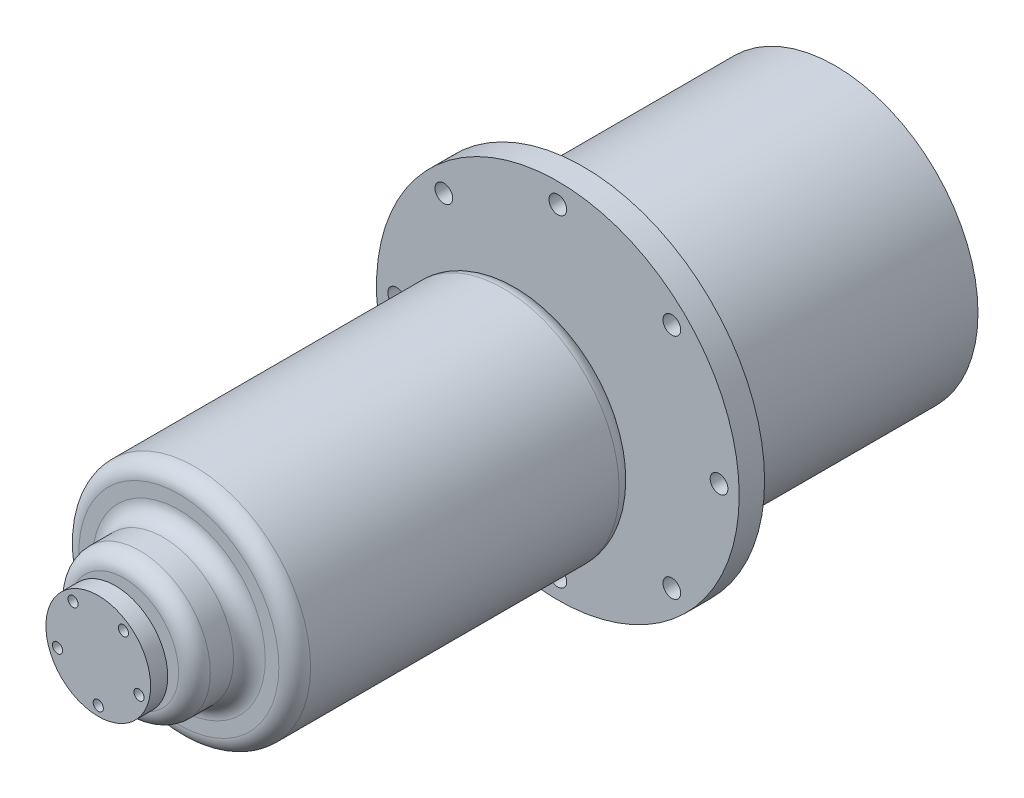
from build123d import *

# Parameters (mm, degrees)
SKETCH1_R          = 57.15
EXTRUDE1_DEPTH     = 4
SKETCH3_R          = 7.5
EXTRUDE2_DEPTH     = 12.166
SKETCH4_R          = 36.5
EXTRUDE3_DEPTH     = 107.24
SKETCH5_R          = 22.225
EXTRUDE4_DEPTH     = 17.3228
SKETCH6_R          = 9.525
EXTRUDE5_DEPTH     = 2.702052
SKETCH7_R          = 16.5
EXTRUDE6_DEPTH     = 5.3848
SKETCH8_R          = 1.6
CUT_EXTRUDE1_DEPTH = 5.3848
SKETCH10_R         = 2.79
CUT_EXTRUDE2_DEPTH = 8
SKETCH11_R         = 45
EXTRUDE7_DEPTH     = 79.4
FILLET1_R          = 5


with BuildPart() as part:
    # Sketch1 → Extrude1 (new body, symmetric)
    with BuildSketch(Plane.XY):
        Circle(SKETCH1_R)
    extrude(amount=EXTRUDE1_DEPTH, both=True)

    # Sketch3 → Extrude2 (add)
    with BuildSketch(Plane.XY.offset(4)):
        Circle(SKETCH3_R)
    extrude(amount=EXTRUDE2_DEPTH)

    # Sketch4 → Extrude3 (add)
    with BuildSketch(Plane.XY.offset(16.166)):
        Circle(SKETCH4_R)
    extrude(amount=EXTRUDE3_DEPTH)

    # Sketch5 → Extrude4 (add)
    with BuildSketch(Plane.XY.offset(123.406)):
        Circle(SKETCH5_R)
    extrude(amount=EXTRUDE4_DEPTH)

    # Sketch6 → Extrude5 (add)
    with BuildSketch(Plane.XY.offset(140.7288)):
        Circle(SKETCH6_R)
    extrude(amount=EXTRUDE5_DEPTH)

    # Sketch7 → Extrude6 (add)
    with BuildSketch(Plane.XY.offset(143.430852)):
        Circle(SKETCH7_R)
    extrude(amount=EXTRUDE6_DEPTH)

    # Sketch8 → Cut-Extrude1 (cut)
    with BuildSketch(Plane.XY.offset(148.815652)):
        with Locations((-7.935100906, 10.921729424)):
            Circle(SKETCH8_R)
        with Locations((7.935100906, 10.921729424)):
            Circle(SKETCH8_R)
        with Locations((12.83926297, -4.171729424)):
            Circle(SKETCH8_R)
        with Locations((0, -13.5)):
            Circle(SKETCH8_R)
        with Locations((-12.83926297, -4.171729424)):
            Circle(SKETCH8_R)
    extrude(amount=-CUT_EXTRUDE1_DEPTH, mode=Mode.SUBTRACT)

    # Sketch10 → Cut-Extrude2 (cut)
    with BuildSketch(Plane(origin=(0, 0, -4), x_dir=(-1, 0, 0), z_dir=(0, 0, -1))):
        with Locations((0, 50.8)):
            Circle(SKETCH10_R)
        with Locations((35.921024484, 35.921024484)):
            Circle(SKETCH10_R)
        with Locations((50.8, 0)):
            Circle(SKETCH10_R)
        with Locations((35.921024484, -35.921024484)):
            Circle(SKETCH10_R)
        with Locations((0, -50.8)):
            Circle(SKETCH10_R)
        with Locations((-35.921024484, -35.921024484)):
            Circle(SKETCH10_R)
        with Locations((-50.8, 0)):
            Circle(SKETCH10_R)
        with Locations((-35.921024484, 35.921024484)):
            Circle(SKETCH10_R)
    extrude(amount=-CUT_EXTRUDE2_DEPTH, mode=Mode.SUBTRACT)

    # Sketch11 → Extrude7 (add)
    with BuildSketch(Plane(origin=(0, 0, -4), x_dir=(-1, 0, 0), z_dir=(0, 0, -1))):
        with Locations(Location((0, 0, 0), (0, 0, 180))):  # turned: the seam where the file's is
            Circle(SKETCH11_R)
    extrude(amount=EXTRUDE7_DEPTH)

    # Fillet1
    fillet1_edges = [part.edges().sort_by_distance(p)[0] for p in [
        (-36.5, 0, 123.406),
        (-22.225, 0, 123.406),
        (-22.225, 0, 140.7288),
        (-36.5, 0, 16.166),
    ]]
    fillet(fillet1_edges, radius=FILLET1_R)


solid = part.part
